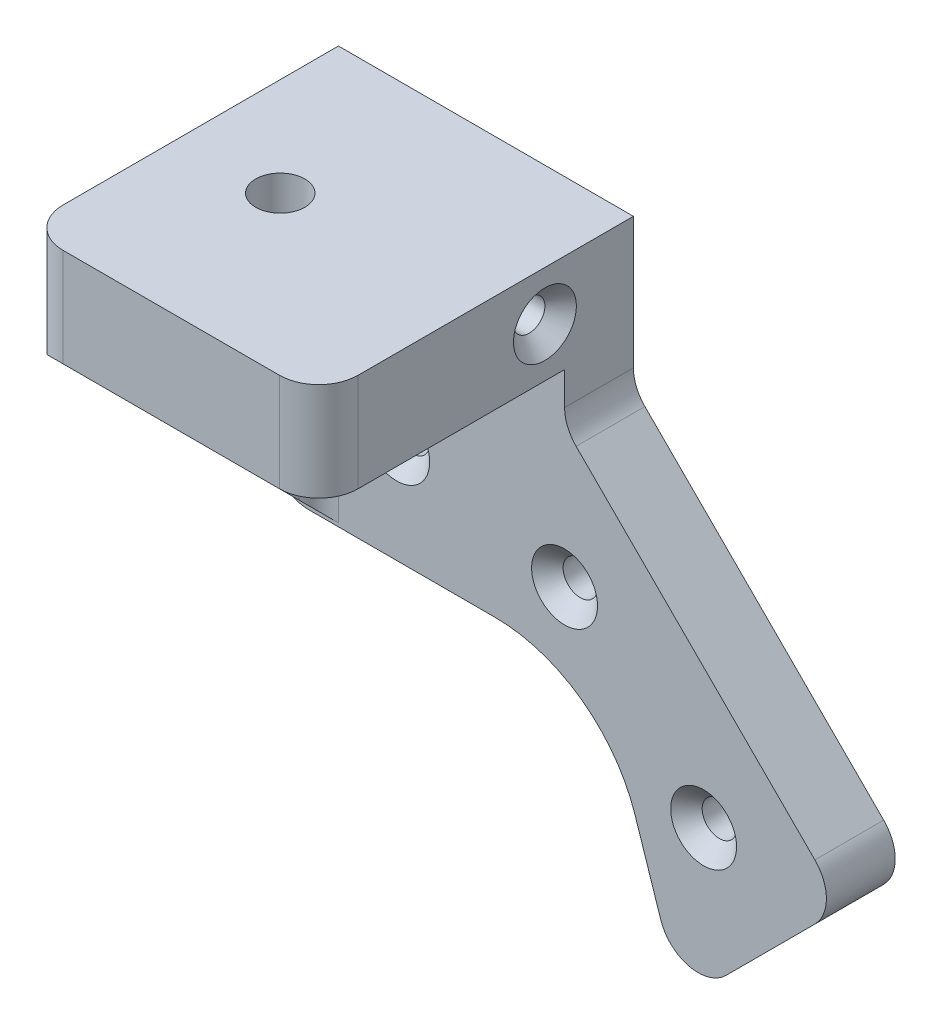
from build123d import *

# Parameters (mm, degrees)
BOSS_EXTRUDE1_DEPTH      = 5
BOSS_EXTRUDE1_DEPTH_BACK = 2
SKETCH3_W                = 30
SKETCH3_H                = 10
BOSS_EXTRUDE2_DEPTH      = 25
SKETCH4_R                = 2.5
CUT_EXTRUDE1_DEPTH       = 83.331203834
RIB1_REACH               = 76.683
SKETCH6_WALL_W           = 186.72160491
SKETCH6_WALL_H           = 5
CUT_EXTRUDE2_DEPTH       = 7
CUT_EXTRUDE3_DEPTH       = 5
FILLET1_R                = 4
SKETCH9_R                = 1.75
CUT_EXTRUDE4_DEPTH       = 60.485369609
CHAMFER1_SIZE            = 1.6
FILLET2_R                = 4
SKETCH10_R               = 1.6
CUT_EXTRUDE5_DEPTH       = 52.293180378
CUT_EXTRUDE6_DEPTH       = 4
CHAMFER2_SIZE            = 1.6
FILLET3_R                = 2


with BuildPart() as part:
    # Sketch1 → Boss-Extrude1 (new, two sides)
    with BuildSketch(Plane.XY) as boss_extrude1_sk:
        Polygon((15, 27.5), (15, 12.5), (43.284271247, -15.784271247), (23.284271247, -35.784271247), (15, -27.5), (-15, -27.5), (-15, 27.5), align=None)
    extrude(amount=BOSS_EXTRUDE1_DEPTH)
    extrude(boss_extrude1_sk.sketch, amount=-BOSS_EXTRUDE1_DEPTH_BACK)

    # Sketch3 → Boss-Extrude2 (add)
    with BuildSketch(Plane.XY.offset(5)):
        with Locations((0, 22.5)):
            Rectangle(SKETCH3_W, SKETCH3_H)
    extrude(amount=BOSS_EXTRUDE2_DEPTH)

    # Sketch4 → Cut-Extrude1 (cut, through all)
    with BuildSketch(Plane(origin=(0, 27.5, 0), x_dir=(1, 0, 0), z_dir=(0, 1, 0))):
        with Locations(Location((-5, -13.9175, 0), (0, 0, 270))):
            Circle(SKETCH4_R)
    extrude(amount=-CUT_EXTRUDE1_DEPTH, mode=Mode.SUBTRACT)

    # Sketch6 wall → Rib1 (add, up to next)
    with BuildSketch(Plane(origin=(-15, 5, 17.5), x_dir=(0, -0.707106781187, -0.707106781187), z_dir=(0, -0.707106781187, 0.707106781187)), mode=Mode.PRIVATE) as rib1_sk1:
        with Locations((0, 2.5)):
            Rectangle(SKETCH6_WALL_W, SKETCH6_WALL_H)
    rib1_tool1 = extrude(rib1_sk1.sketch, amount=-RIB1_REACH, mode=Mode.PRIVATE) - part.part
    add(rib1_tool1.solids().sort_by_distance((-15, 5, 17.5))[0])

    # Sketch7 → Cut-Extrude2 (cut)
    with BuildSketch(Plane.XY.offset(5)):
        with BuildLine():
            Line((22.174744155, -18.158867896), (26.819805153, -32.248737342))
            Line((26.819805153, -32.248737342), (23.284271247, -35.784271247))
            Line((23.284271247, -35.784271247), (-15, -27.5))
            Line((-15, -27.5), (-15, -7.855339059))
            Line((-15, -7.855339059), (7.928932188, -7.855339059))
            ThreePointArc((7.928932188, -7.855339059), (16.719635588, -10.701182004), (22.174744155, -18.158867896))
        make_face()
    extrude(amount=-CUT_EXTRUDE2_DEPTH, mode=Mode.SUBTRACT)

    # Sketch8 → Cut-Extrude3 (cut)
    with BuildSketch(Plane(origin=(0, 17.5, 0), x_dir=(-1, 0, 0), z_dir=(0, -1, 0))):
        Polygon((0.265727793, -13.9175), (2.632863896, -18.0175), (7.367136104, -18.0175), (9.734272207, -13.9175), (7.367136104, -9.8175), (2.632863896, -9.8175), align=None)
    extrude(amount=-CUT_EXTRUDE3_DEPTH, mode=Mode.SUBTRACT)

    # Fillet1
    fillet1_edges = [part.edges().sort_by_distance(p)[0] for p in [
        (-15, 22.5, 30),
        (15, 22.5, 30),
    ]]
    fillet(fillet1_edges, radius=FILLET1_R)

    # Sketch9 → Cut-Extrude4 (cut, through all)
    with BuildSketch(Plane.XY.offset(5)):
        with Locations((15, -1.642135624)):
            Circle(SKETCH9_R)
        with Locations((29.142135624, -15.784271247)):
            Circle(SKETCH9_R)
        with Locations((-2.071067812, 2.5)):
            Circle(SKETCH9_R)
    extrude(amount=-CUT_EXTRUDE4_DEPTH, mode=Mode.SUBTRACT)

    # Chamfer1
    chamfer1_edges = [part.edges().sort_by_distance(p)[0] for p in [
        (-3.821067812, 2.5, 5),
        (27.392135624, -15.784271247, 5),
        (13.25, -1.642135624, 5),
    ]]
    chamfer(chamfer1_edges, length=CHAMFER1_SIZE)

    # Fillet2
    fillet2_edges = [part.edges().sort_by_distance(p)[0] for p in [
        (15, 12.5, 1.5),
        (43.284271247, -15.784271247, 1.5),
        (26.819805153, -32.248737342, 1.5),
        (-15, -7.855339059, 1.5),
    ]]
    fillet(fillet2_edges, radius=FILLET2_R)

    # Sketch10 → Cut-Extrude5 (cut, through all)
    with BuildSketch(Plane(origin=(15, 0, 0), x_dir=(0, 0, -1), z_dir=(1, 0, 0))):
        with Locations(Location((-7, 22.5, 0), (0, 0, 90))):
            Circle(SKETCH10_R)
    extrude(amount=-CUT_EXTRUDE5_DEPTH, mode=Mode.SUBTRACT)

    # Sketch11 → Cut-Extrude6 (cut)
    with BuildSketch(Plane.ZY.offset(15)):
        Polygon((8.58771324, 19.75), (10.175426481, 22.5), (8.58771324, 25.25), (5.41228676, 25.25), (3.824573519, 22.5), (5.41228676, 19.75), align=None)
    extrude(amount=-CUT_EXTRUDE6_DEPTH, mode=Mode.SUBTRACT)

    # Chamfer2
    chamfer2_edges = [part.edges().sort_by_distance(p)[0] for p in [
        (15, 20.9, 7),
    ]]
    chamfer(chamfer2_edges, length=CHAMFER2_SIZE)

    # Fillet3
    fillet3_edges = [part.edges().sort_by_distance(p)[0] for p in [
        (-10, 5, 5),
    ]]
    fillet(fillet3_edges, radius=FILLET3_R)


solid = part.part
